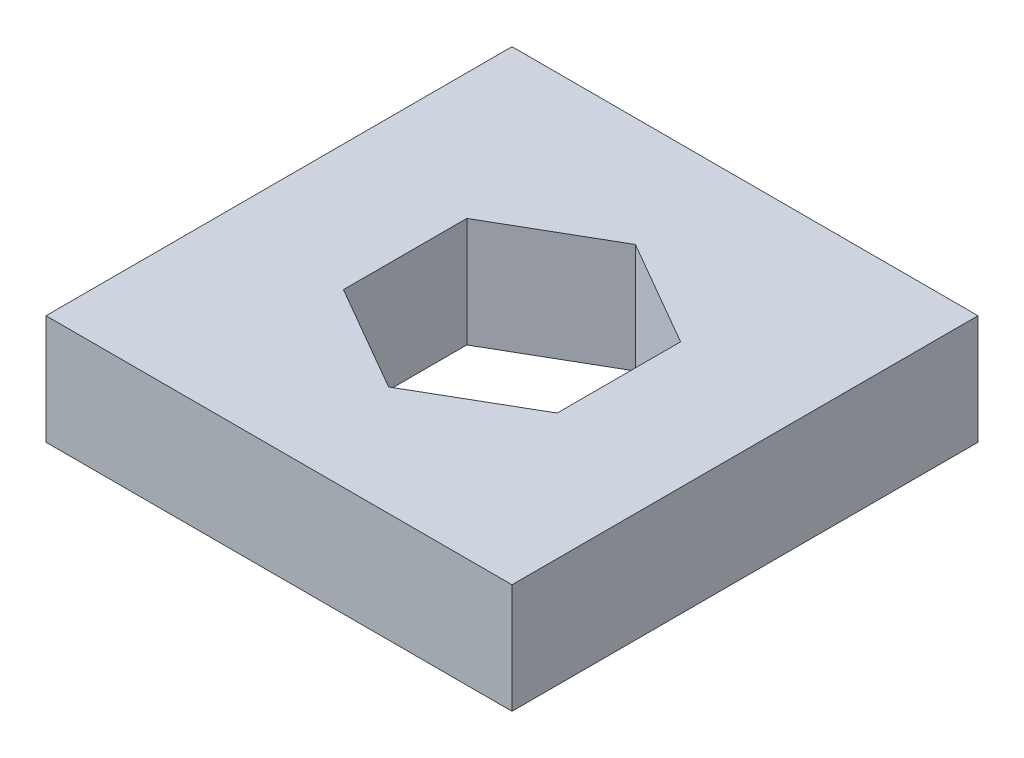
from build123d import *

# Parameters (mm, degrees)
SKETCH1_W           = 26.998079416
SKETCH1_H           = 26.998079416
BOSS_EXTRUDE1_DEPTH = 6.35


with BuildPart() as part:
    # Sketch1 → Boss-Extrude1 (new body)
    with BuildSketch(Plane(origin=(0, 0, 0), x_dir=(1, 0, 0), z_dir=(0, 1, 0))):
        Rectangle(SKETCH1_W, SKETCH1_H)
        Polygon((6.19125, 3.574519854), (0, 7.149039708), (-6.19125, 3.574519854), (-6.19125, -3.574519854), (0, -7.149039708), (6.19125, -3.574519854), align=None, mode=Mode.SUBTRACT)
    extrude(amount=-BOSS_EXTRUDE1_DEPTH)


solid = part.part
